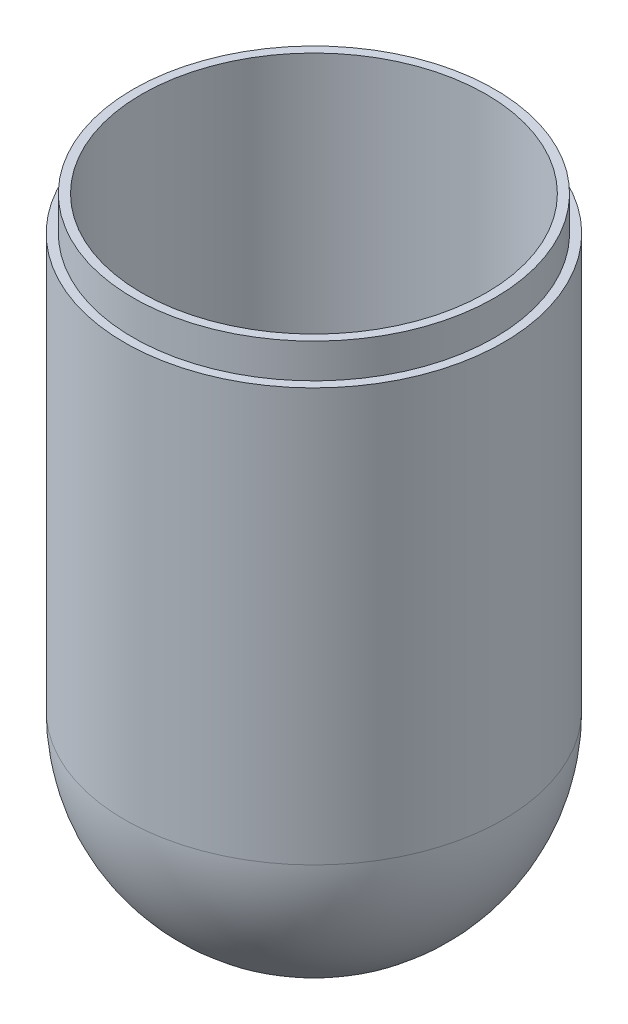
from build123d import *

# Parameters (mm, degrees)
SKETCH3_R           = 69.85
CUT_EXTRUDE1_DEPTH  = 12.7
SKETCH4_R           = 66.675
SKETCH4_R_2         = 63.5
BOSS_EXTRUDE2_DEPTH = 12.7
SKETCH5_R           = 68.2625
SKETCH5_R_2         = 66.675
BOSS_EXTRUDE3_DEPTH = 9.525
SKETCH7_R           = 68.2625
SKETCH7_R_2         = 66.675
CUT_EXTRUDE2_DEPTH  = 1.5875
SKETCH12_R          = 68.2625
SKETCH12_R_2        = 66.675
CUT_EXTRUDE3_DEPTH  = 7.9375


with BuildPart() as part:
    # Sketch1 → Revolve1 (revolve)
    with BuildSketch(Plane.XY):
        with BuildLine():
            Line((63.5, 0), (63.5, 152.4))
            Line((63.5, 152.4), (66.675, 152.4))
            Line((66.675, 152.4), (66.675, 165.1))
            Line((66.675, 165.1), (69.85, 165.1))
            Line((69.85, 165.1), (69.85, 152.4))
            Line((69.85, 152.4), (69.85, 0))
            ThreePointArc((69.85, 0), (49.391408666, -49.391408666), (0, -69.85))
            Line((0, -69.85), (0, -63.5))
            ThreePointArc((0, -63.5), (44.901280605, -44.901280605), (63.5, 0))
        make_face()
    revolve(axis=Axis((0, -63.5, 0), (0, -1, 0)))

    # Sketch3 → Cut-Extrude1 (cut)
    with BuildSketch(Plane(origin=(0, 165.1, 0), x_dir=(1, 0, 0), z_dir=(0, 1, 0))):
        Circle(SKETCH3_R)
    extrude(amount=-CUT_EXTRUDE1_DEPTH, mode=Mode.SUBTRACT)

    # Sketch4 → Boss-Extrude2 (add)
    with BuildSketch(Plane(origin=(0, 152.4, 0), x_dir=(1, 0, 0), z_dir=(0, 1, 0))):
        Circle(SKETCH4_R)
        Circle(SKETCH4_R_2, mode=Mode.SUBTRACT)
    extrude(amount=BOSS_EXTRUDE2_DEPTH)

    # Sketch5 → Boss-Extrude3 (add)
    with BuildSketch(Plane(origin=(0, 165.1, 0), x_dir=(1, 0, 0), z_dir=(0, 1, 0))):
        Circle(SKETCH5_R)
        Circle(SKETCH5_R_2, mode=Mode.SUBTRACT)
    extrude(amount=-BOSS_EXTRUDE3_DEPTH)

    # Sketch7 → Cut-Extrude2 (cut)
    with BuildSketch(Plane(origin=(0, 165.1, 0), x_dir=(1, 0, 0), z_dir=(0, 1, 0))):
        Circle(SKETCH7_R)
        Circle(SKETCH7_R_2, mode=Mode.SUBTRACT)
    extrude(amount=-CUT_EXTRUDE2_DEPTH, mode=Mode.SUBTRACT)

    # Sketch12 → Cut-Extrude3 (cut)
    with BuildSketch(Plane(origin=(0, 163.5125, 0), x_dir=(1, 0, 0), z_dir=(0, 1, 0))):
        Circle(SKETCH12_R)
        Circle(SKETCH12_R_2, mode=Mode.SUBTRACT)
    extrude(amount=-CUT_EXTRUDE3_DEPTH, mode=Mode.SUBTRACT)


solid = part.part
